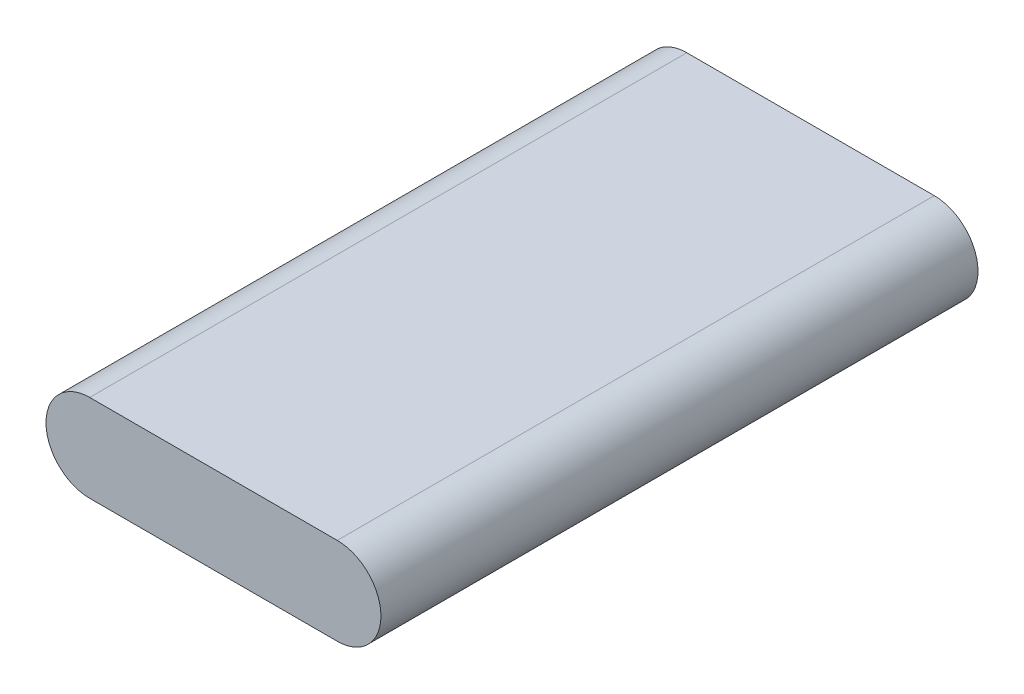
from build123d import *

# Parameters (mm, degrees)
BOSS_EXTRUDE1_DEPTH = 104.14


with BuildPart() as part:
    # Sketch1 → Boss-Extrude1 (new body)
    with BuildSketch(Plane.XY):
        with BuildLine():
            Line((0, 15.24), (43.18, 15.24))
            ThreePointArc((43.18, 15.24), (50.8, 7.62), (43.18, 0))
            Line((43.18, 0), (0, 0))
            ThreePointArc((0, 0), (-7.62, 7.62), (0, 15.24))
        make_face()
    extrude(amount=BOSS_EXTRUDE1_DEPTH)


solid = part.part
